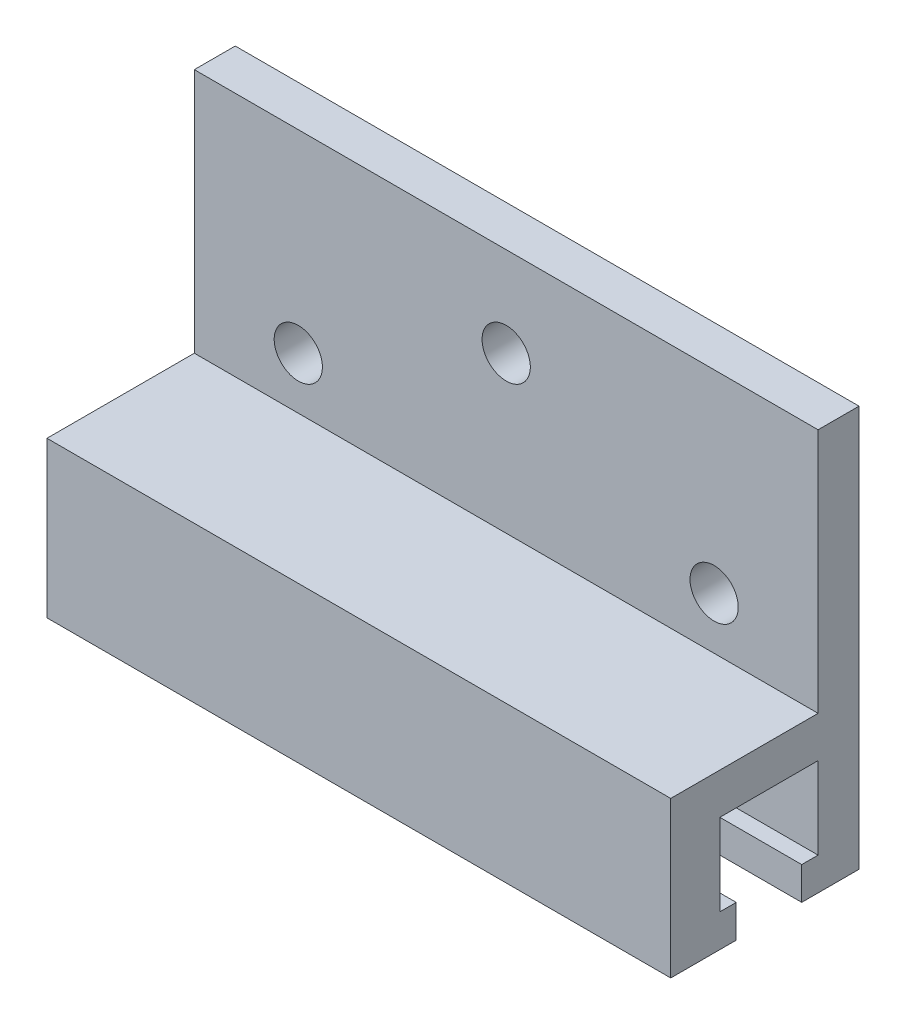
from build123d import *

# Parameters (mm, degrees)
BOSS_EXTRUDE1_DEPTH       = 38.1
F_4_CLEARANCE_HOLE1_D     = 2.9464
F_4_CLEARANCE_HOLE1_DEPTH = 6.35
F_4_CLEARANCE_HOLE1_TIP   = 0.885187864


with BuildPart() as part:
    # Sketch1 → Boss-Extrude1 (new body)
    with BuildSketch(Plane(origin=(0, 0, 0), x_dir=(0, 0, -1), z_dir=(1, 0, 0))):
        Polygon((-6, -4.5), (-2, -4.5), (-2, -2.5), (-3, -2.5), (-3, 2.5), (3, 2.5), (3, -2.5), (2, -2.5), (2, -4.5), (5.5, -4.5), (5.5, 4.583333333), (5.5, 20), (3, 20), (3, 5), (-6, 5), align=None)
    extrude(amount=BOSS_EXTRUDE1_DEPTH)

    # #4 Clearance Hole1
    with Locations(Plane(origin=(0, 0, -5.5), x_dir=(-1, 0, 0), z_dir=(0, 0, -1))):
        with Locations((-19.05, 14.525), (-31.75, 8.175), (-6.35, 8.175)):
            Hole(F_4_CLEARANCE_HOLE1_D / 2, depth=F_4_CLEARANCE_HOLE1_DEPTH)
            with Locations((0, 0, -(F_4_CLEARANCE_HOLE1_DEPTH + F_4_CLEARANCE_HOLE1_TIP / 2))):  # 118° drill point
                Cone(0, F_4_CLEARANCE_HOLE1_D / 2, F_4_CLEARANCE_HOLE1_TIP, mode=Mode.SUBTRACT)


solid = part.part
